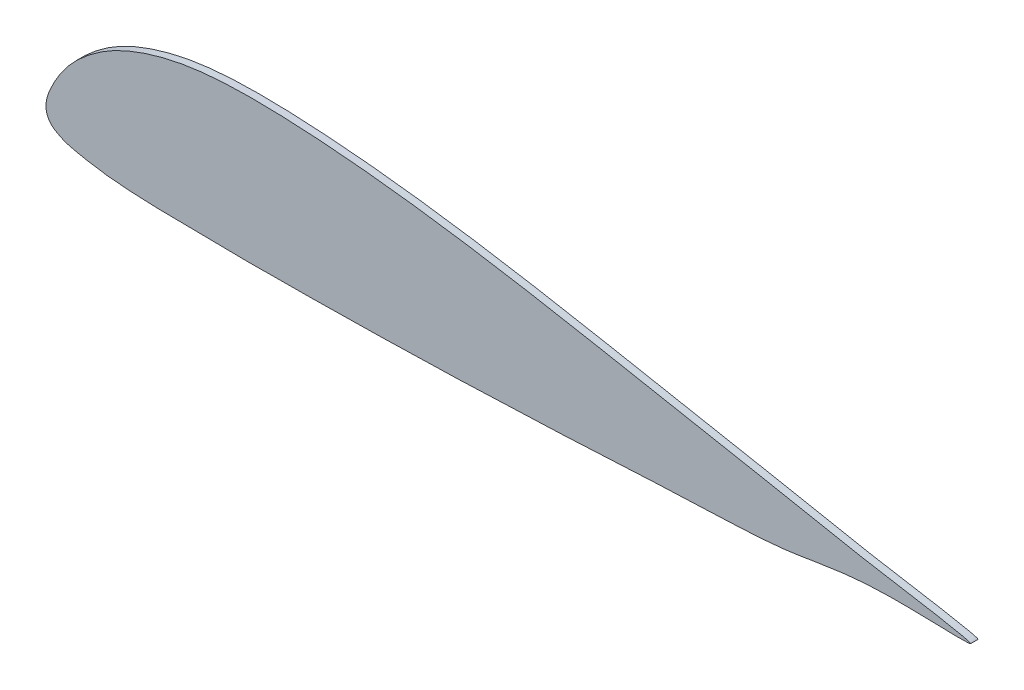
from build123d import *

# Parameters (mm, degrees)
BOSS_EXTRUDE33_DEPTH = 4
BOSS_EXTRUDE34_DEPTH = 4


with BuildPart() as part:
    # Sketch11 → Boss-Extrude33 (new body)
    with BuildSketch(Plane.XY):
        with BuildLine():
            ThreePointArc((71, 52.609074807), (61.100505063, 48.508569744), (57, 38.609074807))
            ThreePointArc((57, 38.609074807), (71, 24.609074807), (85, 38.609074807))
            ThreePointArc((85, 38.609074807), (80.899494937, 48.508569744), (71, 52.609074807))
        make_face()
    extrude(amount=BOSS_EXTRUDE33_DEPTH)

    # Sketch11_11 → Boss-Extrude34 (add)
    with BuildSketch(Plane.XY):
        with BuildLine():
            add(Edge.make_bspline(
                [(7.866428189, 37.560085444), (9.349195933, 39.779065614), (12.103487325, 43.475517412), (16.915935985, 48.515040412), (21.617666438, 52.706946157), (26.642159371, 56.545568948), (31.662679073, 59.906825849), (36.989219458, 62.956699278), (42.861934298, 65.782634772), (49.016837863, 68.27302087), (55.447830013, 70.481551152), (61.497182478, 72.230215977), (68.046745376, 73.817699849), (74.397894009, 75.0510161), (80.882482078, 76.008254254), (86.7438297, 76.669666073), (93.185858745, 77.199271443), (100.873467484, 77.595445639), (109.531029417, 77.772960846), (119.540449473, 77.70557625), (130.116670867, 77.386447579), (141.136423807, 76.837588784), (151.918170622, 76.121191589), (163.323143638, 75.200014952), (175.958123105, 73.98696157), (190.05754678, 72.414474165), (206.582344437, 70.322494401), (223.849998754, 67.856762862), (240.49037061, 65.243431898), (253.817395036, 63.016551795), (268.670487025, 60.432091543), (285.232031152, 57.425508895), (303.893779286, 53.925708793), (320.011133365, 50.860108071), (334.611432618, 48.07372379), (347.931865553, 45.539086625), (362.655250182, 42.765384592), (376.820025473, 40.102729948), (391.306330775, 37.349577919), (404.141083587, 34.848652183), (419.345736354, 31.81039935), (436.363954131, 28.525755535), (455.999670421, 25.109629602), (476.567739048, 21.577355275), (486.734086077, 19.998065802), (503.199535964, 16.482847328), (494.045443438, 16.078970503), (487.893099973, 16.345651072), (477.382967159, 16.566779325), (465.767026362, 16.813799081), (452.74352491, 16.818636795), (439.17413754, 16.114742804), (425.264325471, 14.464252943), (412.041731394, 12.210907367), (396.927202205, 9.953910024), (381.325737555, 8.814536841), (365.963725519, 8.188608845), (351.799027155, 7.706123882), (338.722591283, 7.149538403), (326.138738132, 6.505634779), (315.786058687, 5.9504901), (307.253260404, 5.491569809), (297.411514353, 4.979626029), (286.856508579, 4.471363696), (277.288264205, 4.043936213), (269.185495433, 3.696346467), (261.45540833, 3.37510163), (251.858473678, 2.990400519), (241.259764139, 2.575386953), (231.979319172, 2.227308135), (223.450553442, 1.925923576), (216.537698653, 1.695410287), (207.316113689, 1.411330557), (198.265588962, 1.169515988), (188.83204481, 0.960506401), (181.194391154, 0.811797963), (173.300774394, 0.674971798), (165.598027616, 0.553110889), (157.184877056, 0.427740207), (148.255486382, 0.29637314), (137.665890196, 0.139932701), (127.332975975, 0.024689451), (116.035852959, -0.012293936), (106.276096056, 0.023009938), (96.777462409, 0.10088258), (88.69121587, 0.189140044), (80.066702423, 0.303091928), (71.531938589, 0.422867633), (61.897859117, 0.59322565), (53.011370152, 0.862691356), (44.034947677, 1.334120773), (36.217291445, 1.959520211), (28.305200826, 2.911658294), (21.138062661, 4.15286774), (14.980640459, 5.475978741), (10.127448243, 6.709317186), (6.495262055, 8.523106886), (3.416883643, 10.358060049), (1.236182063, 12.921845427), (0.04229169, 16.149642334), (-0.107746476, 19.668256316), (0.848747163, 24.133543154), (2.848098091, 28.674695825), (5.205494886, 33.388345671), (6.938591531, 36.171566471), (7.866428189, 37.560085444)],
                knots=[0, 0, 0, 0, 0.007706972, 0.013288227, 0.020114312, 0.025893272, 0.031551897, 0.03756632, 0.043618409, 0.050376014, 0.056745984, 0.063264954, 0.068569627, 0.076221343, 0.081955851, 0.087512386, 0.093268004, 0.100636625, 0.109759074, 0.118293519, 0.129566794, 0.140340402, 0.150183662, 0.16079871, 0.173412415, 0.186871094, 0.201803841, 0.221556428, 0.237286489, 0.250490924, 0.260611426, 0.280863818, 0.299143427, 0.315492968, 0.32828576, 0.342106856, 0.354686027, 0.371592203, 0.383765332, 0.397312235, 0.409371575, 0.428650667, 0.447017705, 0.468574148, 0.482904755, 0.490873644, 0.494014251, 0.502595482, 0.511845232, 0.523193048, 0.536597072, 0.549342878, 0.562479897, 0.577046941, 0.588116309, 0.606637018, 0.622219343, 0.632561705, 0.647602331, 0.660050176, 0.668982328, 0.677569471, 0.684749623, 0.69746805, 0.70811365, 0.71243391, 0.720910408, 0.73047652, 0.740195846, 0.751569148, 0.757320213, 0.764863378, 0.77156164, 0.783987564, 0.791032832, 0.798835688, 0.806068143, 0.813852522, 0.821103036, 0.830388814, 0.839665457, 0.851715326, 0.860257388, 0.872319413, 0.879925567, 0.887713816, 0.895693836, 0.904856656, 0.912385681, 0.923545255, 0.930552381, 0.938365914, 0.946209281, 0.953580928, 0.959372486, 0.964436982, 0.967974777, 0.971074454, 0.974748022, 0.97742975, 0.980891009, 0.984768491, 0.990533763, 0.995177389, 1, 1, 1, 1], degree=3))
        make_face()
    extrude(amount=BOSS_EXTRUDE34_DEPTH)


solid = part.part
